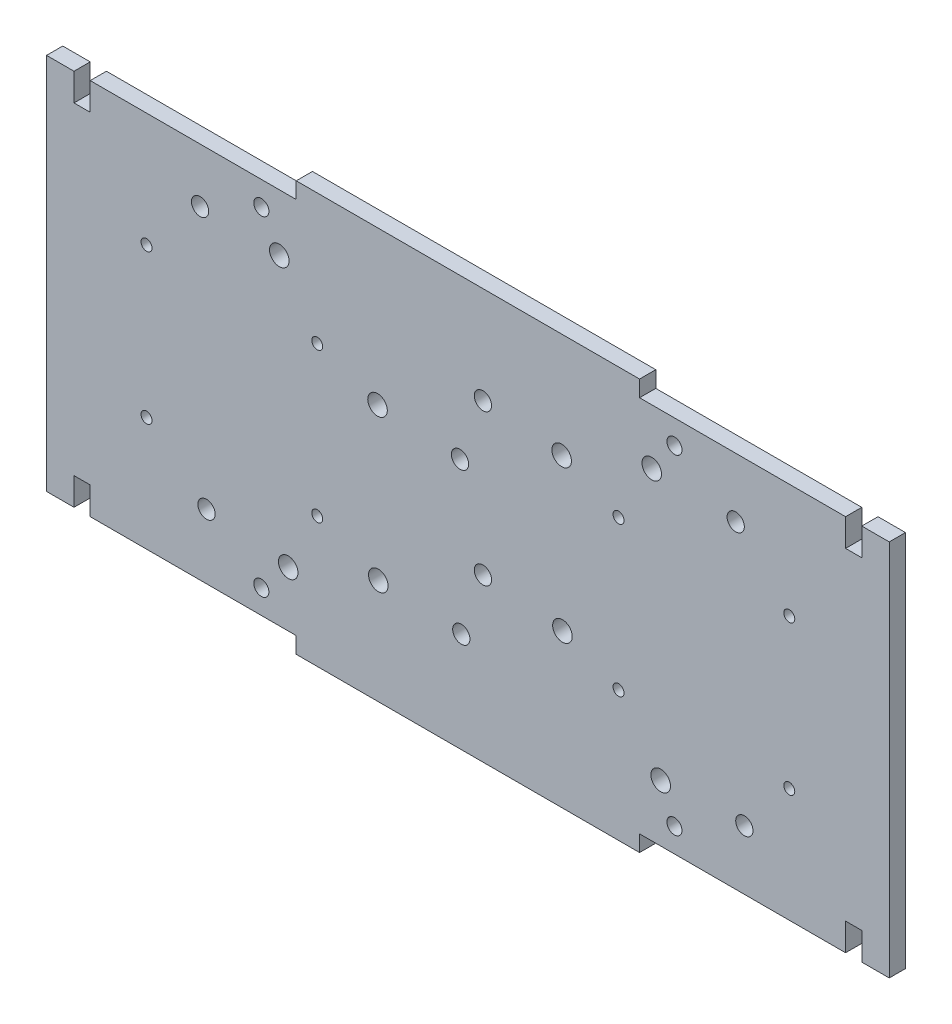
from build123d import *

# Parameters (mm, degrees)
BOSS_EXTRUDE1_DEPTH = 2.9972
SKETCH9_R           = 1.397
CUT_EXTRUDE3_DEPTH  = 3.9972
SKETCH10_R          = 1.80975
CUT_EXTRUDE4_DEPTH  = 3.9972
SKETCH11_R          = 1.6
CUT_EXTRUDE5_DEPTH  = 3.9972
SKETCH12_R          = 1.016
CUT_EXTRUDE6_DEPTH  = 3.9972


with BuildPart() as part:
    # Sketch3 → Boss-Extrude1 (new body)
    with BuildSketch(Plane.XY):
        Polygon((38.1, 0), (38.1, -2.9972), (101.6, -2.9972), (101.6, 0), (139.7, 0), (139.7, 5.08), (142.6972, 5.08), (142.6972, 0), (147.7772, 0), (147.7772, 69.85), (142.6972, 69.85), (142.6972, 64.77), (139.7, 64.77), (139.7, 69.85), (101.6, 69.85), (101.6, 72.8472), (38.1, 72.8472), (38.1, 69.85), (0, 69.85), (0, 64.77), (-2.9972, 64.77), (-2.9972, 69.85), (-8.0772, 69.85), (-8.0772, 0), (-2.9972, 0), (-2.9972, 5.08), (0, 5.08), (0, 0), align=None)
    extrude(amount=BOSS_EXTRUDE1_DEPTH)

    # Sketch9 → Cut-Extrude3 (cut, through all)
    with BuildSketch(Plane(origin=(0, 0, 0), x_dir=(-1, 0, 0), z_dir=(0, 0, -1))):
        with Locations((-31.6484, 4.445)):
            Circle(SKETCH9_R)
        with Locations((-108.0516, 65.405)):
            Circle(SKETCH9_R)
        with Locations((-108.0516, 4.445)):
            Circle(SKETCH9_R)
        with Locations((-31.6484, 65.405)):
            Circle(SKETCH9_R)
    extrude(amount=-CUT_EXTRUDE3_DEPTH, mode=Mode.SUBTRACT)

    # Sketch10 → Cut-Extrude4 (cut, through all)
    with BuildSketch(Plane(origin=(0, 0, 0), x_dir=(-1, 0, 0), z_dir=(0, 0, -1))):
        with Locations((-53.1368, 44.48175)):
            Circle(SKETCH10_R)
        with Locations((-34.967367815, 59.34075)):
            Circle(SKETCH10_R)
        with Locations((-87.189767815, 53.40985)):
            Circle(SKETCH10_R)
        with Locations((-103.85425, 59.63285)):
            Circle(SKETCH10_R)
        with Locations((-87.335817815, 25.36825)):
            Circle(SKETCH10_R)
        with Locations((-105.50525, 10.50925)):
            Circle(SKETCH10_R)
        with Locations((-53.28285, 16.44015)):
            Circle(SKETCH10_R)
        with Locations((-36.618367815, 10.21715)):
            Circle(SKETCH10_R)
    extrude(amount=-CUT_EXTRUDE4_DEPTH, mode=Mode.SUBTRACT)

    # Sketch11 → Cut-Extrude5 (cut, through all)
    with BuildSketch(Plane(origin=(0, 0, 0), x_dir=(-1, 0, 0), z_dir=(0, 0, -1))):
        with Locations((-119.38, 58.864027758)):
            Circle(SKETCH11_R)
        with Locations((-120.98, 10.985972242)):
            Circle(SKETCH11_R)
        with Locations((-68.629534614, 15.487902261)):
            Circle(SKETCH11_R)
        with Locations((-68.390649314, 43.386879551)):
            Circle(SKETCH11_R)
        with Locations((-21.50999995, 11.950503851)):
            Circle(SKETCH11_R)
        with Locations((-20.32, 59.840503852)):
            Circle(SKETCH11_R)
        with Locations((-72.629999995, 54.890503798)):
            Circle(SKETCH11_R)
        with Locations((-72.629999966, 26.990503798)):
            Circle(SKETCH11_R)
    extrude(amount=-CUT_EXTRUDE5_DEPTH, mode=Mode.SUBTRACT)

    # Sketch12 → Cut-Extrude6 (cut, through all)
    with BuildSketch(Plane.XY.offset(2.9972)):
        with Locations((10.414, 21.1074)):
            Circle(SKETCH12_R)
        with Locations((10.414, 48.7426)):
            Circle(SKETCH12_R)
        with Locations((41.9862, 21.1074)):
            Circle(SKETCH12_R)
        with Locations((41.9862, 48.7426)):
            Circle(SKETCH12_R)
        with Locations((129.286, 21.1074)):
            Circle(SKETCH12_R)
        with Locations((129.286, 48.7426)):
            Circle(SKETCH12_R)
        with Locations((97.7138, 21.1074)):
            Circle(SKETCH12_R)
        with Locations((97.7138, 48.7426)):
            Circle(SKETCH12_R)
    extrude(amount=-CUT_EXTRUDE6_DEPTH, mode=Mode.SUBTRACT)


solid = part.part
